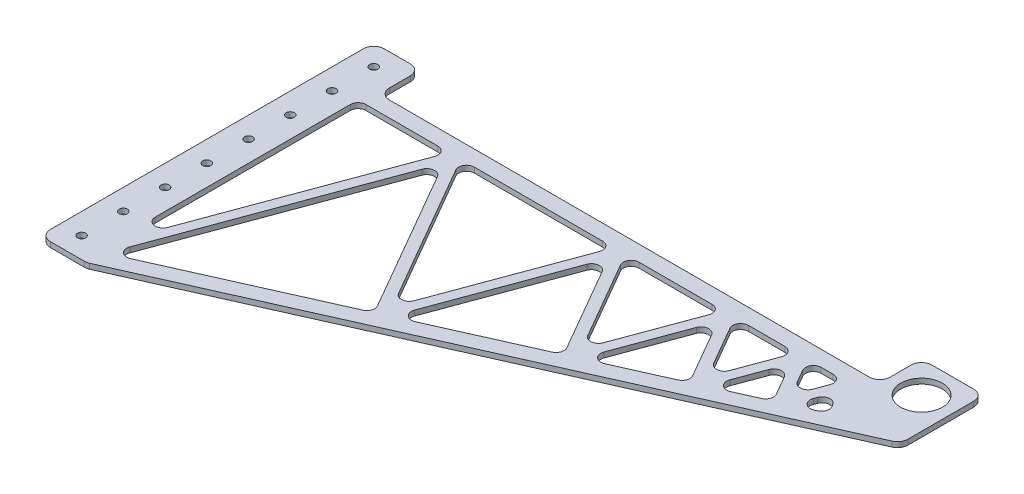
from build123d import *

# Parameters (mm, degrees)
BOSS_EXTRUDE1_DEPTH = 1.5875
SKETCH2_R           = 2.4892
SKETCH2_R_2         = 12.7
CUT_EXTRUDE1_DEPTH  = 4.175
FILLET1_R           = 6.35
CUT_EXTRUDE2_DEPTH  = 4.175
FILLET2_R           = 4.7625


with BuildPart() as part:
    # Sketch1 → Boss-Extrude1 (new body, symmetric)
    with BuildSketch(Plane(origin=(0, 0, 0), x_dir=(1, 0, 0), z_dir=(0, 1, 0))):
        Polygon((0, 0), (0, 203.2), (28.575, 203.2), (28.575, 177.8), (333.375, 177.8), (333.375, 203.2), (371.475, 203.2), (371.475, 152.668916192), (28.575, 0), align=None)
    extrude(amount=BOSS_EXTRUDE1_DEPTH, both=True)

    # Sketch2 → Cut-Extrude1 (cut, through all)
    with BuildSketch(Plane(origin=(0, 1.5875, 0), x_dir=(1, 0, 0), z_dir=(0, 1, 0))):
        with Locations((12.7, 190.5)):
            Circle(SKETCH2_R)
        with Locations((12.7, 165.1)):
            Circle(SKETCH2_R)
        with Locations((12.7, 139.7)):
            Circle(SKETCH2_R)
        with Locations((12.7, 114.3)):
            Circle(SKETCH2_R)
        with Locations((12.7, 88.9)):
            Circle(SKETCH2_R)
        with Locations((12.7, 63.5)):
            Circle(SKETCH2_R)
        with Locations((12.7, 38.1)):
            Circle(SKETCH2_R)
        with Locations((12.7, 12.7)):
            Circle(SKETCH2_R)
        with Locations((352.425, 184.15)):
            Circle(SKETCH2_R_2)
    extrude(amount=-CUT_EXTRUDE1_DEPTH, mode=Mode.SUBTRACT)

    # Fillet1
    fillet1_edges = [part.edges().sort_by_distance(p)[0] for p in [
        (0, 0, 0),
        (0, 0, -203.2),
        (28.575, 0, -203.2),
        (28.575, 0, -177.8),
        (333.375, 0, -177.8),
        (333.375, 0, -203.2),
        (371.475, 0, -203.2),
        (371.475, 0, -152.668916192),
        (28.575, 0, 0),
    ]]
    fillet(fillet1_edges, radius=FILLET1_R)

    # Sketch3 → Cut-Extrude2 (cut, through all)
    with BuildSketch(Plane(origin=(0, 1.5875, 0), x_dir=(1, 0, 0), z_dir=(0, 1, 0))):
        Polygon((29.450902816, 10.816387612), (142.430270713, 61.118043048), (84.86301023, 160.827463057), align=None)
        Polygon((25.4, 18.175792916), (80.844662076, 168.275), (25.4, 168.275), align=None)
        Polygon((144.713091094, 69.864082163), (181.064782686, 168.275), (87.89552119, 168.275), align=None)
        Polygon((149.39765716, 64.220123355), (222.156526072, 96.614458906), (185.08313084, 160.827463057), align=None)
        Polygon((224.439346453, 105.360498021), (247.679131457, 168.275), (188.1156418, 168.275), align=None)
        Polygon((229.123912518, 99.716539213), (275.149004512, 120.208230413), (251.697479611, 160.827463057), align=None)
        Polygon((277.431824893, 128.954269529), (291.956382724, 168.275), (254.729990571, 168.275), align=None)
        Polygon((282.116390959, 123.310310721), (310.372065706, 135.890547641), (295.974730878, 160.827463057), align=None)
        Polygon((312.654886087, 144.636586756), (321.386603328, 168.275), (299.007241838, 168.275), align=None)
        Polygon((325.404951482, 160.827463057), (317.339452153, 138.992627948), (333.784143729, 146.314276359), align=None)
    extrude(amount=-CUT_EXTRUDE2_DEPTH, mode=Mode.SUBTRACT)

    # Fillet2
    fillet2_edges = [part.edges().sort_by_distance(p)[0] for p in [
        (277.431824893, 0, -128.954269529),
        (254.729990571, 0, -168.275),
        (291.956382724, 0, -168.275),
        (229.123912518, 0, -99.716539213),
        (251.697479611, 0, -160.827463057),
        (275.149004512, 0, -120.208230413),
        (312.654886087, 0, -144.636586756),
        (299.007241838, 0, -168.275),
        (321.386603328, 0, -168.275),
        (282.116390959, 0, -123.310310721),
        (295.974730878, 0, -160.827463057),
        (310.372065706, 0, -135.890547641),
        (25.4, 0, -18.175792916),
        (25.4, 0, -168.275),
        (80.844662076, 0, -168.275),
        (144.713091094, 0, -69.864082163),
        (87.89552119, 0, -168.275),
        (181.064782686, 0, -168.275),
        (224.439346453, 0, -105.360498021),
        (188.1156418, 0, -168.275),
        (247.679131457, 0, -168.275),
        (149.39765716, 0, -64.220123355),
        (185.08313084, 0, -160.827463057),
        (222.156526072, 0, -96.614458906),
        (325.404951482, 0, -160.827463057),
        (333.784143729, 0, -146.314276359),
        (317.339452153, 0, -138.992627948),
        (29.450902816, 0, -10.816387612),
        (84.86301023, 0, -160.827463057),
        (142.430270713, 0, -61.118043048),
    ]]
    fillet(fillet2_edges, radius=FILLET2_R)


solid = part.part
